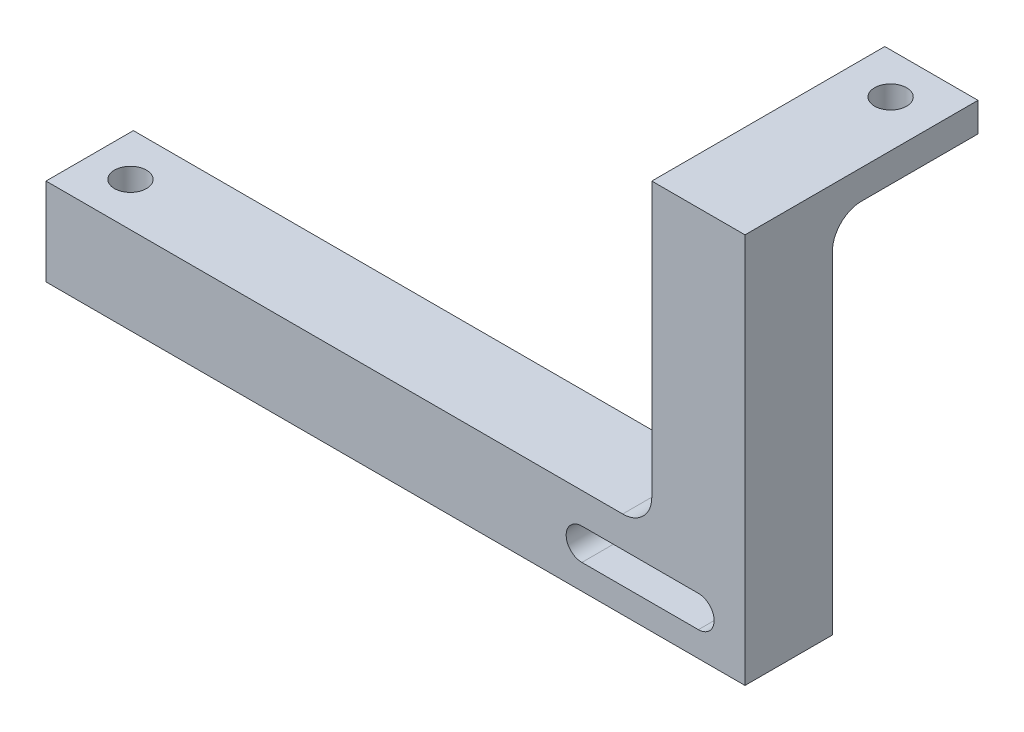
from build123d import *

# Parameters (mm, degrees)
BOSS_EXTRUDE1_DEPTH  = 15
SKETCH2_W            = 16
SKETCH2_H            = 5
BOSS_EXTRUDE2_DEPTH  = 40
CUT_EXTRUDE1_DEPTH   = 45
M5_CLEARANCE_HOLE1_D = 5.5
FILLET1_R            = 5


with BuildPart() as part:
    # Sketch1 → Boss-Extrude1 (new body)
    with BuildSketch(Plane.XY):
        Polygon((0, 0), (-120, 0), (-120, 15), (-16, 15), (-16, 62), (0, 62), align=None)
    extrude(amount=BOSS_EXTRUDE1_DEPTH)

    # Sketch2 → Boss-Extrude2 (add)
    with BuildSketch(Plane.XY.offset(15)):
        with Locations((-8, 64.5)):
            Rectangle(SKETCH2_W, SKETCH2_H)
    extrude(amount=-BOSS_EXTRUDE2_DEPTH)

    # Sketch3 → Cut-Extrude1 (cut)
    with BuildSketch(Plane.XY.offset(15)):
        with BuildLine():
            Line((-28, 9.7), (-8, 9.7))
            ThreePointArc((-8, 9.7), (-5.3, 7), (-8, 4.3))
            Line((-8, 4.3), (-28, 4.3))
            ThreePointArc((-28, 4.3), (-30.7, 7), (-28, 9.7))
        make_face()
    extrude(amount=-CUT_EXTRUDE1_DEPTH, mode=Mode.SUBTRACT)

    # M5 Clearance Hole1 (through all)
    with Locations(Plane(origin=(0, 67, 0), x_dir=(1, 0, 0), z_dir=(0, 1, 0))):
        with Locations((-8, 18), (-113, -7.5)):
            Hole(M5_CLEARANCE_HOLE1_D / 2)

    # Fillet1
    fillet1_edges = [part.edges().sort_by_distance(p)[0] for p in [
        (-16, 15, 7.5),
        (-8, 62, 0),
    ]]
    fillet(fillet1_edges, radius=FILLET1_R)


solid = part.part
